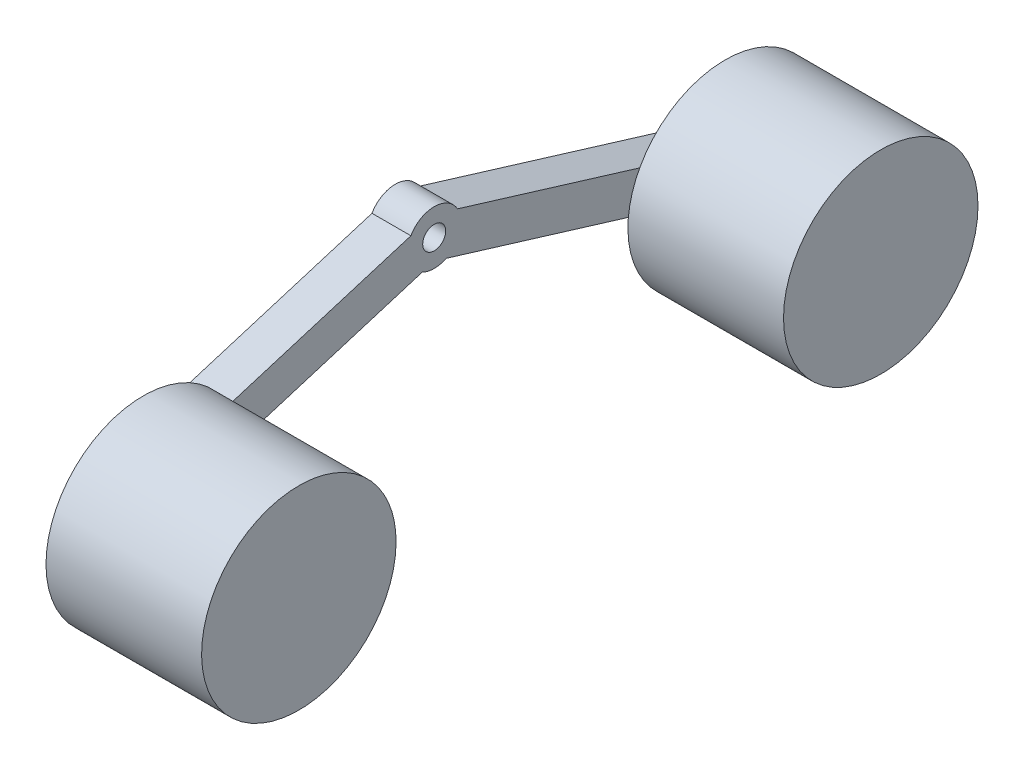
from build123d import *

# Parameters (mm, degrees)
SKETCH1_R           = 15
BOSS_EXTRUDE1_DEPTH = 50.8
SKETCH2_R           = 127
BOSS_EXTRUDE2_DEPTH = 203.2
BOSS_EXTRUDE3_START = -4
SKETCH3_R           = 2
BOSS_EXTRUDE3_DEPTH = 5
BOSS_EXTRUDE4_START = -15
SKETCH3_2_R         = 2
BOSS_EXTRUDE4_DEPTH = 5


with BuildPart() as part:
    # Sketch1 → Boss-Extrude1 (new body)
    with BuildSketch(Plane(origin=(0, 0, 0), x_dir=(0, 0, -1), z_dir=(1, 0, 0))):
        with BuildLine():
            ThreePointArc((-387.415853794, -91.706685848), (-404.293314152, -123.415853794), (-372.584146206, -140.293314152))
            Line((-372.584146206, -140.293314152), (-15.614846066, -31.32373832))
            ThreePointArc((-15.614846066, -31.32373832), (0, -35), (15.614846066, -31.32373832))
            Line((15.614846066, -31.32373832), (372.584146206, -140.293314152))
            ThreePointArc((372.584146206, -140.293314152), (404.293314152, -123.415853794), (387.415853794, -91.706685848))
            Line((387.415853794, -91.706685848), (30.446553653, 17.262889985))
            ThreePointArc((30.446553653, 17.262889985), (0, 35), (-30.446553653, 17.262889985))
            Line((-30.446553653, 17.262889985), (-387.415853794, -91.706685848))
        make_face()
        Circle(SKETCH1_R, mode=Mode.SUBTRACT)
    extrude(amount=BOSS_EXTRUDE1_DEPTH)

    # Sketch2 → Boss-Extrude2 (add)
    with BuildSketch(Plane(origin=(50.8, 0, 0), x_dir=(0, 0, -1), z_dir=(1, 0, 0))):
        with Locations((-380, -116)):
            Circle(SKETCH2_R)
    boss_extrude2 = extrude(amount=BOSS_EXTRUDE2_DEPTH)

    # Sketch3 → Boss-Extrude3 (add)
    with BuildSketch(Plane.ZY.offset(BOSS_EXTRUDE3_START)):
        with BuildLine():
            Line((372.826777317, -80.979847323), (371.07500083, -86.718425469))
            Line((371.07500083, -86.718425469), (385.421446196, -91.097866686))
            Line((385.421446196, -91.097866686), (387.173222683, -85.35928854))
            ThreePointArc((387.173222683, -85.35928854), (382.189720608, -75.996345249), (372.826777317, -80.979847323))
        make_face()
        with Locations((380, -83.169567931)):
            Circle(SKETCH3_R, mode=Mode.SUBTRACT)
    boss_extrude3 = extrude(amount=-BOSS_EXTRUDE3_DEPTH)

    # Sketch3_2 → Boss-Extrude4 (add)
    with BuildSketch(Plane.ZY.offset(BOSS_EXTRUDE4_START)):
        with BuildLine():
            Line((372.826777317, -80.979847323), (371.07500083, -86.718425469))
            Line((371.07500083, -86.718425469), (385.421446196, -91.097866686))
            Line((385.421446196, -91.097866686), (387.173222683, -85.35928854))
            ThreePointArc((387.173222683, -85.35928854), (382.189720608, -75.996345249), (372.826777317, -80.979847323))
        make_face()
        with Locations((380, -83.169567931)):
            Circle(SKETCH3_2_R, mode=Mode.SUBTRACT)
    boss_extrude4 = extrude(amount=-BOSS_EXTRUDE4_DEPTH)

    # Mirror1: Boss-Extrude2, Boss-Extrude3, Boss-Extrude4 across plane
    add(boss_extrude2.mirror(Plane.XY))
    add(boss_extrude3.mirror(Plane.XY))
    add(boss_extrude4.mirror(Plane.XY))


solid = part.part
